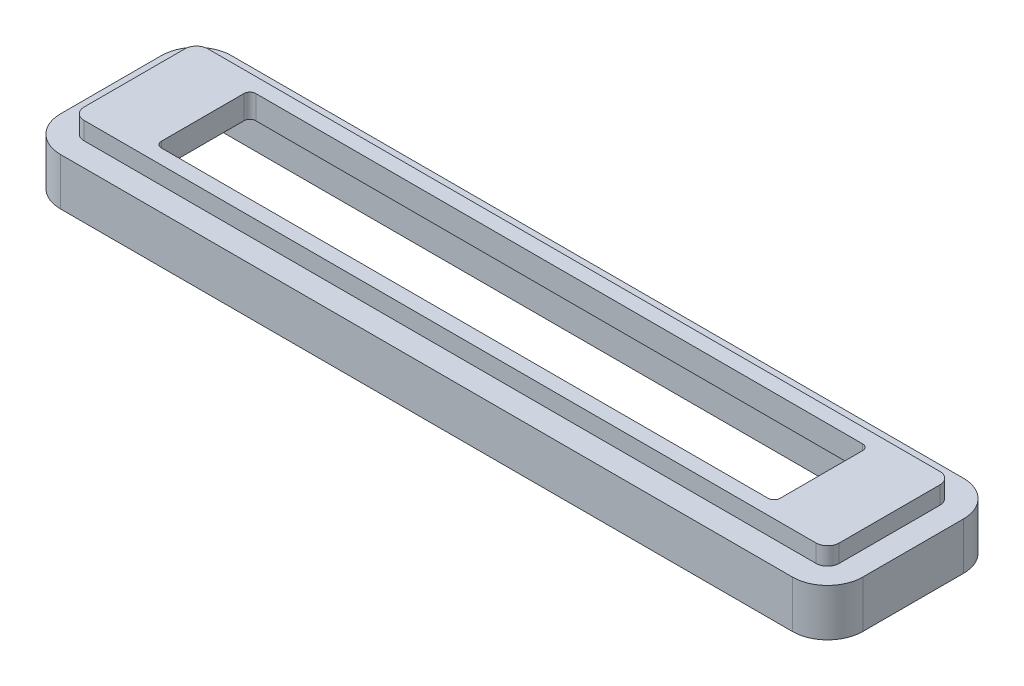
from build123d import *

# Parameters (mm, degrees)
BOSS_EXTRUDE1_DEPTH = 2
BOSS_EXTRUDE2_START = 0.5
BOSS_EXTRUDE2_DEPTH = 4


with BuildPart() as part:
    # Sketch1 → Boss-Extrude1 (new body)
    with BuildSketch(Plane(origin=(0, 0, 0), x_dir=(1, 0, 0), z_dir=(0, 1, 0))):
        with BuildLine():
            Line((-31.018542474, -5.25), (31.018542474, -5.25))
            ThreePointArc((31.018542474, -5.25), (31.712537746, -4.962537746), (32, -4.268542474))
            Line((32, -4.268542474), (32, 4.268542474))
            ThreePointArc((32, 4.268542474), (31.712537746, 4.962537746), (31.018542474, 5.25))
            Line((31.018542474, 5.25), (-31.018542474, 5.25))
            ThreePointArc((-31.018542474, 5.25), (-31.712537746, 4.962537746), (-32, 4.268542474))
            Line((-32, 4.268542474), (-32, -4.268542474))
            ThreePointArc((-32, -4.268542474), (-31.712537746, -4.962537746), (-31.018542474, -5.25))
        make_face()
        with BuildLine():
            Line((-26.215, 3.50000032), (-26.215, -3.50000032))
            ThreePointArc((-26.215, -3.50000032), (-26.068553391, -3.853553711), (-25.715, -4.00000032))
            Line((-25.715, -4.00000032), (25.715, -4.00000032))
            ThreePointArc((25.715, -4.00000032), (26.068553391, -3.853553711), (26.215, -3.50000032))
            Line((26.215, -3.50000032), (26.215, 3.50000032))
            ThreePointArc((26.215, 3.50000032), (26.068553391, 3.853553711), (25.715, 4.00000032))
            Line((25.715, 4.00000032), (-25.715, 4.00000032))
            ThreePointArc((-25.715, 4.00000032), (-26.068553391, 3.853553711), (-26.215, 3.50000032))
        make_face(mode=Mode.SUBTRACT)
    extrude(amount=BOSS_EXTRUDE1_DEPTH)

    # Sketch2 → Boss-Extrude2 (add)
    with BuildSketch(Plane(origin=(0, 0, 0), x_dir=(1, 0, 0), z_dir=(0, 1, 0)).offset(BOSS_EXTRUDE2_START)):
        with BuildLine():
            Line((-31.018542474, -7.25), (31.018542474, -7.25))
            ThreePointArc((31.018542474, -7.25), (33.126751308, -6.376751308), (34, -4.268542474))
            Line((34, -4.268542474), (34, 4.268542474))
            ThreePointArc((34, 4.268542474), (33.126751308, 6.376751308), (31.018542474, 7.25))
            Line((31.018542474, 7.25), (-31.018542474, 7.25))
            ThreePointArc((-31.018542474, 7.25), (-33.126751308, 6.376751308), (-34, 4.268542474))
            Line((-34, 4.268542474), (-34, -4.268542474))
            ThreePointArc((-34, -4.268542474), (-33.126751308, -6.376751308), (-31.018542474, -7.25))
        make_face()
        with BuildLine():
            Line((-31.018542474, -5.25), (31.018542474, -5.25))
            ThreePointArc((31.018542474, -5.25), (31.712537746, -4.962537746), (32, -4.268542474))
            Line((32, -4.268542474), (32, 4.268542474))
            ThreePointArc((32, 4.268542474), (31.712537746, 4.962537746), (31.018542474, 5.25))
            Line((31.018542474, 5.25), (-31.018542474, 5.25))
            ThreePointArc((-31.018542474, 5.25), (-31.712537746, 4.962537746), (-32, 4.268542474))
            Line((-32, 4.268542474), (-32, -4.268542474))
            ThreePointArc((-32, -4.268542474), (-31.712537746, -4.962537746), (-31.018542474, -5.25))
        make_face(mode=Mode.SUBTRACT)
    extrude(amount=-BOSS_EXTRUDE2_DEPTH)


solid = part.part
